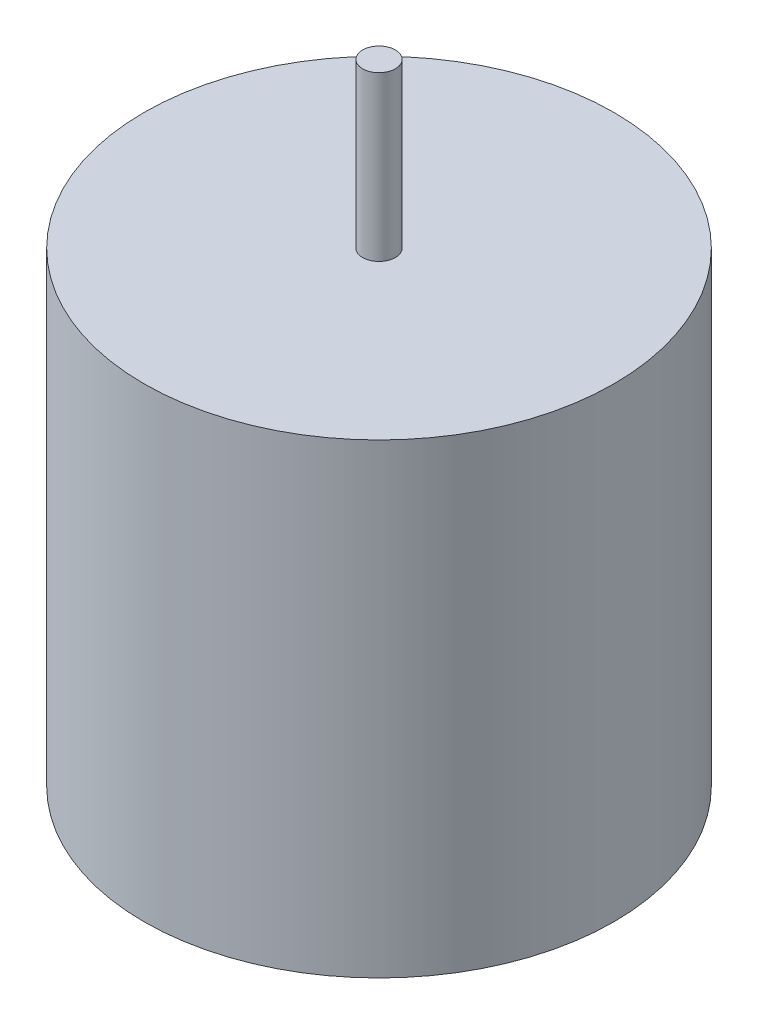
from build123d import *

# Parameters (mm, degrees)
ESQUISSE1_R        = 4
BOSS_EXTRU_1_DEPTH = 40
ESQUISSE2_R        = 57.5
BOSS_EXTRU_2_DEPTH = 114


with BuildPart() as part:
    # Esquisse1 → Boss.-Extru.1 (new body)
    with BuildSketch(Plane(origin=(0, 0, 0), x_dir=(1, 0, 0), z_dir=(0, 1, 0))):
        Circle(ESQUISSE1_R)
    extrude(amount=BOSS_EXTRU_1_DEPTH)

    # Esquisse2 → Boss.-Extru.2 (add)
    with BuildSketch(Plane.XZ):
        Circle(ESQUISSE2_R)
    extrude(amount=BOSS_EXTRU_2_DEPTH)


solid = part.part
